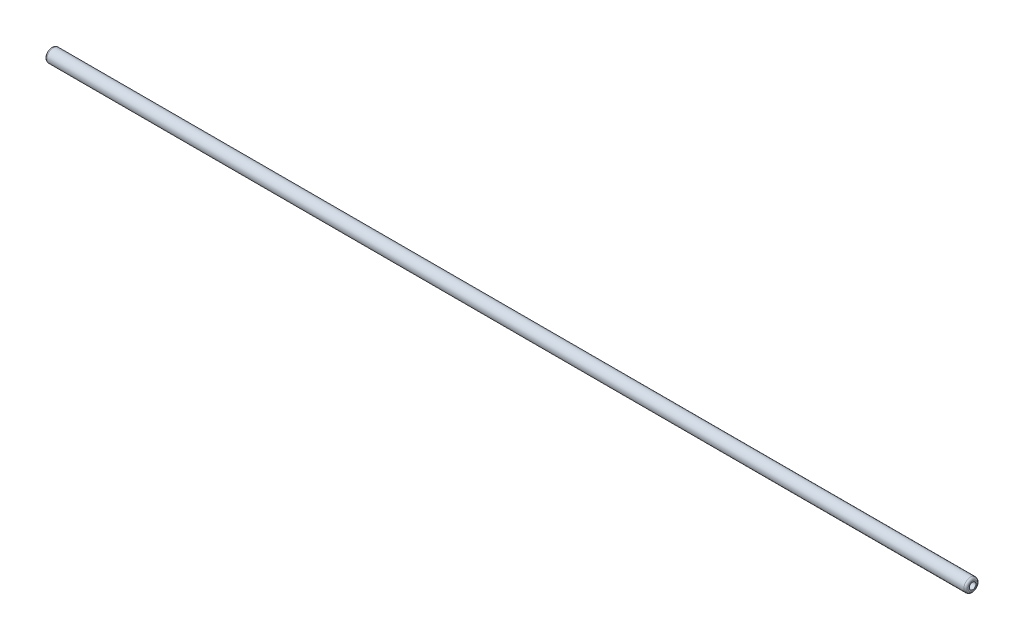
from build123d import *

# Parameters (mm, degrees)
SKETCH_1_R        = 7.9375
SKETCH_1_R_2      = 3.975
EXTRUDE_1_DEPTH   = 550.8625
FILLET_1_R        = 2.5
MOVE_BODY_1_ANGLE = 90


with BuildPart() as part:
    # 스케치1 → 보스-돌출1 (new body, symmetric)
    with BuildSketch(Plane(origin=(0, 0, 0), x_dir=(1, 0, 0), z_dir=(0, 1, 0))):
        Circle(SKETCH_1_R)
        Circle(SKETCH_1_R_2, mode=Mode.SUBTRACT)
    extrude(amount=EXTRUDE_1_DEPTH, both=True)

    # 필렛1
    fillet_1_edges = [part.edges().sort_by_distance(p)[0] for p in [
        (-7.9375, -550.8625, 0),
        (-7.9375, 550.8625, 0),
    ]]
    fillet(fillet_1_edges, radius=FILLET_1_R)


with BuildPart() as part_1:
    # Move Body 1: moved
    add(part.part.rotate(Axis((0, 0, 0), (0, 0, 1)), MOVE_BODY_1_ANGLE))


solid = part_1.part
